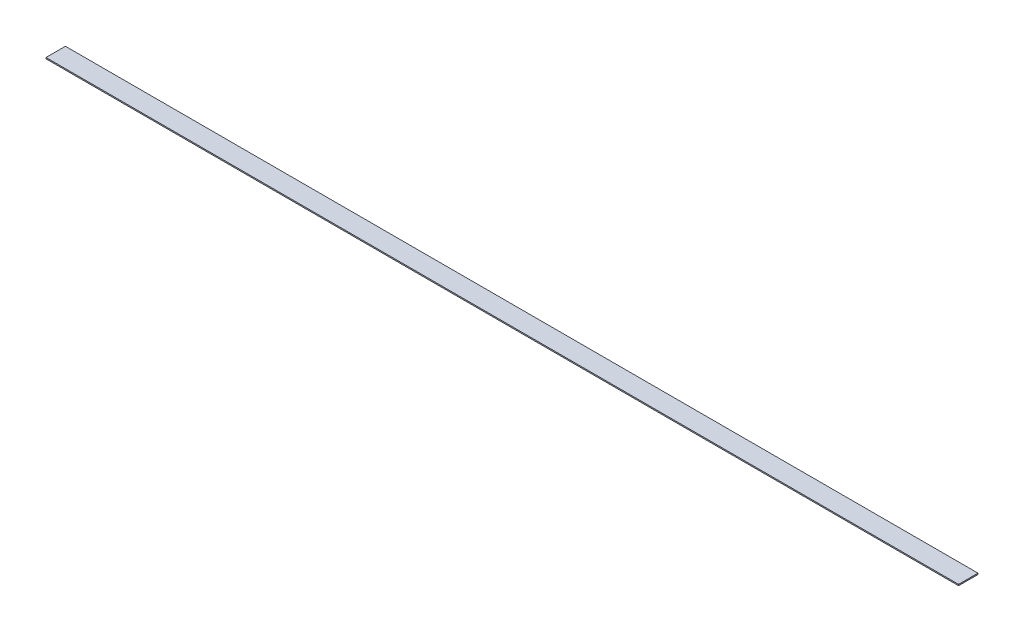
from build123d import *

# Parameters (mm, degrees)
SKETCH1_W           = 1193.8
SKETCH1_H           = 25.4
BOSS_EXTRUDE1_DEPTH = 1.5875


with BuildPart() as part:
    # Sketch1 → Boss-Extrude1 (new body)
    with BuildSketch(Plane(origin=(0, 0, 0), x_dir=(1, 0, 0), z_dir=(0, 1, 0))):
        Rectangle(SKETCH1_W, SKETCH1_H)
    extrude(amount=BOSS_EXTRUDE1_DEPTH)


solid = part.part
